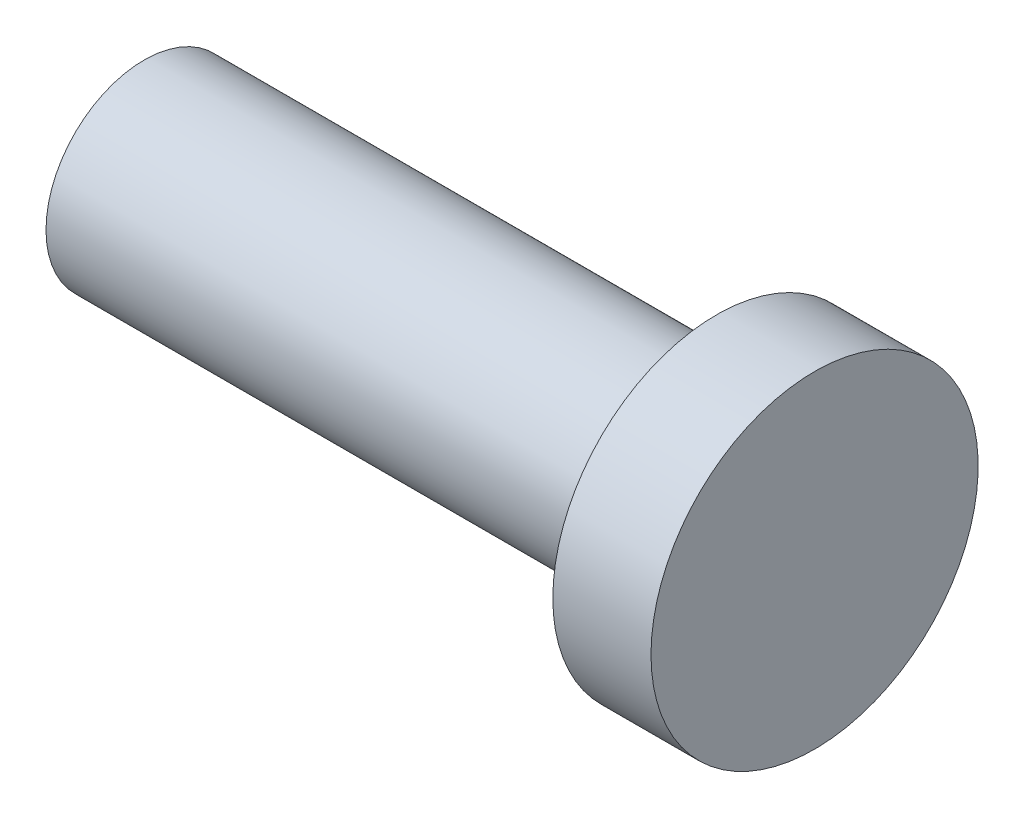
from build123d import *


with BuildPart() as part:
    # Sketch1 → Revolve1 (revolve)
    with BuildSketch(Plane(origin=(0, 0, 0), x_dir=(1, 0, 0), z_dir=(0, 1, 0))):
        Polygon((0, 0), (0, 2.5), (-1.5, 2.5), (-1.5, 1.5), (-10.245483166, 1.5), (-10.245483166, 0), align=None)
    revolve(axis=Axis((-42.210232103, 0, 0), (1, 0, 0)))


solid = part.part
